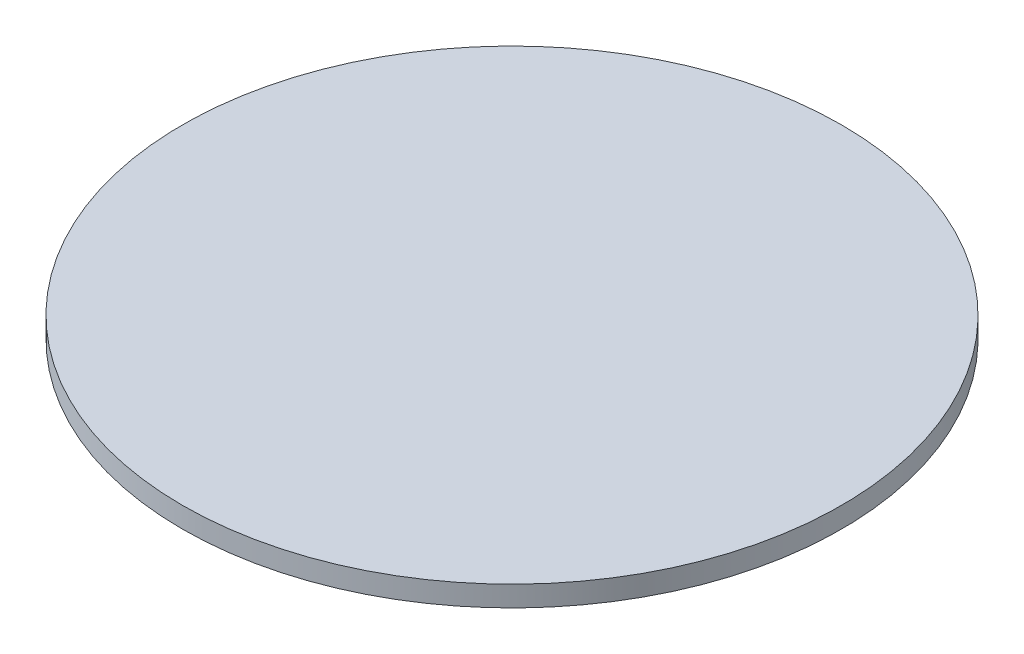
from build123d import *

# Parameters (mm, degrees)
SKETCH1_R           = 50.8
BOSS_EXTRUDE1_DEPTH = 3.175


with BuildPart() as part:
    # Sketch1 → Boss-Extrude1 (new body)
    with BuildSketch(Plane(origin=(0, 0, 0), x_dir=(1, 0, 0), z_dir=(0, 1, 0))):
        Circle(SKETCH1_R)
    extrude(amount=BOSS_EXTRUDE1_DEPTH)


solid = part.part
